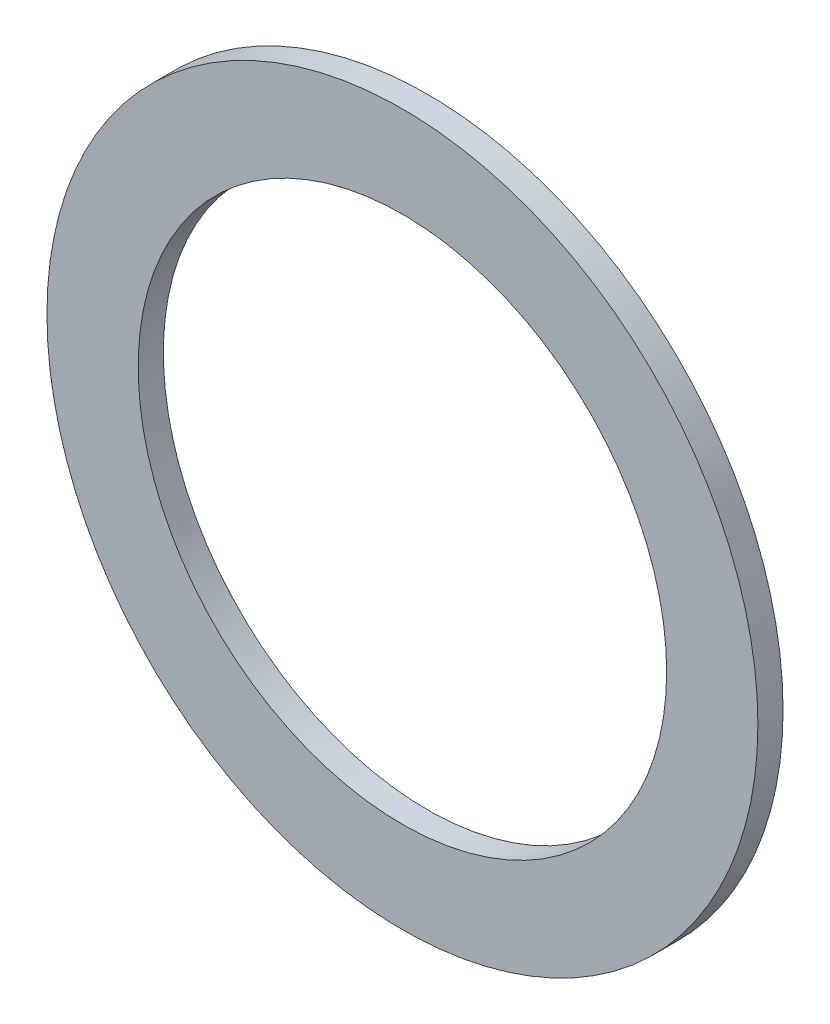
from build123d import *

# Parameters (mm, degrees)
SKETCH1_R          = 14.351
SKETCH1_R_2        = 10.668
BASE_EXTRUDE_DEPTH = 1.016


with BuildPart() as part:
    # Sketch1 → Base-Extrude (new body)
    with BuildSketch(Plane.XY):
        Circle(SKETCH1_R)
        Circle(SKETCH1_R_2, mode=Mode.SUBTRACT)
    extrude(amount=BASE_EXTRUDE_DEPTH)


solid = part.part
